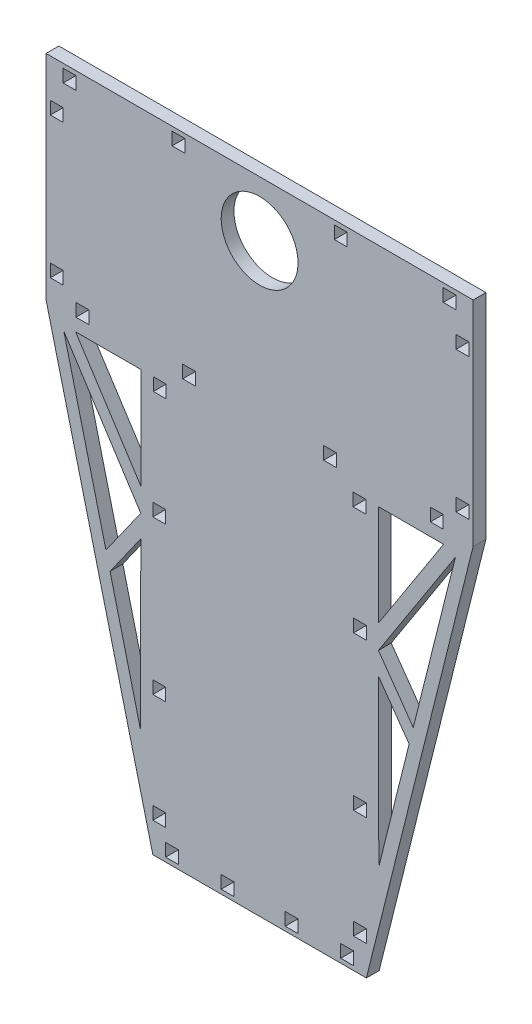
from build123d import *

# Parameters (mm, degrees)
BOSS_EXTRUDE1_DEPTH = 6
SKETCH4_W           = 6
SKETCH4_H           = 6
CUT_EXTRUDE2_DEPTH  = 6
SKETCH5_R           = 18
CUT_EXTRUDE3_DEPTH  = 6


with BuildPart() as part:
    # Sketch1 → Boss-Extrude1 (new body)
    with BuildSketch(Plane.XY):
        Polygon((100, 300), (100, 200), (50, 0), (-50, 0), (-100, 200), (-100, 300), align=None)
    extrude(amount=BOSS_EXTRUDE1_DEPTH)

    # Sketch4 → Cut-Extrude2 (cut)
    with BuildSketch(Plane(origin=(0, 0, 0), x_dir=(-1, 0, 0), z_dir=(0, 0, -1))):
        with Locations((-249.21822542, 247.31110849)):
            Rectangle(SKETCH4_W, SKETCH4_H)
        with Locations((-95, 279)):
            Rectangle(SKETCH4_W, SKETCH4_H)
        with Locations((-95, 213)):
            Rectangle(SKETCH4_W, SKETCH4_H)
        with Locations((-89, 295)):
            Rectangle(SKETCH4_W, SKETCH4_H)
        with Locations((-41, 5)):
            Rectangle(SKETCH4_W, SKETCH4_H)
        with Locations((-38, 295)):
            Rectangle(SKETCH4_W, SKETCH4_H)
        with Locations((-83, 203)):
            Rectangle(SKETCH4_W, SKETCH4_H)
        with Locations((-33, 203)):
            Rectangle(SKETCH4_W, SKETCH4_H)
        with Locations((-15, 5)):
            Rectangle(SKETCH4_W, SKETCH4_H)
        with Locations((-47, 17)):
            Rectangle(SKETCH4_W, SKETCH4_H)
        with Locations((-47, 68)):
            Rectangle(SKETCH4_W, SKETCH4_H)
        with Locations((-46.748754565, 191)):
            Rectangle(SKETCH4_W, SKETCH4_H)
        with Locations((-47, 140)):
            Rectangle(SKETCH4_W, SKETCH4_H)
        with Locations((38, 295)):
            Rectangle(SKETCH4_W, SKETCH4_H)
        with Locations((89, 295)):
            Rectangle(SKETCH4_W, SKETCH4_H)
        with Locations((95, 279)):
            Rectangle(SKETCH4_W, SKETCH4_H)
        with Locations((83, 203)):
            Rectangle(SKETCH4_W, SKETCH4_H)
        with Locations((95, 213)):
            Rectangle(SKETCH4_W, SKETCH4_H)
        with Locations((46.748754565, 191)):
            Rectangle(SKETCH4_W, SKETCH4_H)
        with Locations((47, 140)):
            Rectangle(SKETCH4_W, SKETCH4_H)
        with Locations((47, 68)):
            Rectangle(SKETCH4_W, SKETCH4_H)
        with Locations((47, 17)):
            Rectangle(SKETCH4_W, SKETCH4_H)
        with Locations((41, 5)):
            Rectangle(SKETCH4_W, SKETCH4_H)
        with Locations((15, 5)):
            Rectangle(SKETCH4_W, SKETCH4_H)
        with Locations((33, 203)):
            Rectangle(SKETCH4_W, SKETCH4_H)
        Polygon((55.622098795, 194), (86.171284614, 194), (55.622098795, 146.710661579), align=None)
        Polygon((55.640072778, 135.681178614), (91.684652057, 191.47724198), (71.962334114, 112.587970208), align=None)
        Polygon((70.042546798, 104.908820946), (55.622098795, 125.311288729), (55.832173802, 48.067328963), align=None)
        Polygon((-55.832173802, 48.067328963), (-70.042546798, 104.908820946), (-55.622098795, 125.311288729), align=None)
        Polygon((-71.962334114, 112.587970208), (-55.640072778, 135.681178614), (-91.684652057, 191.47724198), align=None)
        Polygon((-86.171284614, 194), (-55.622098795, 146.710661579), (-55.622098795, 194), align=None)
    extrude(amount=-CUT_EXTRUDE2_DEPTH, mode=Mode.SUBTRACT)

    # Sketch5 → Cut-Extrude3 (cut)
    with BuildSketch(Plane(origin=(0, 0, 0), x_dir=(-1, 0, 0), z_dir=(0, 0, -1))):
        with Locations((0, 274)):
            Circle(SKETCH5_R)
    extrude(amount=-CUT_EXTRUDE3_DEPTH, mode=Mode.SUBTRACT)


solid = part.part
